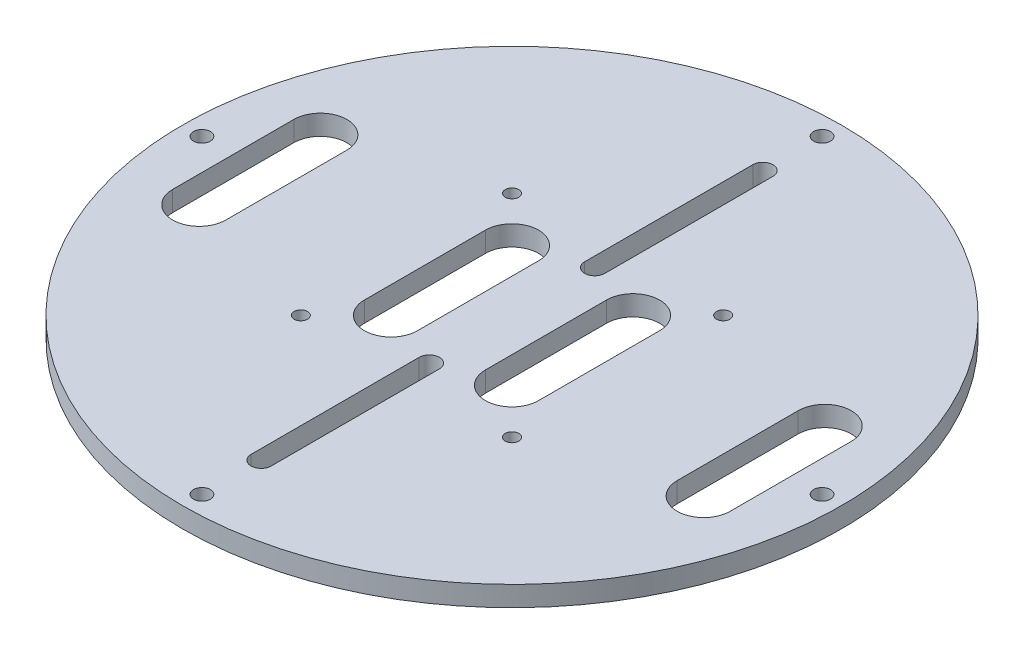
from build123d import *

# Parameters (mm, degrees)
SKETCH_1_R                      = 49
EXTRUDE_1_DEPTH                 = 3
CUT_EXTRUDE_1_DEPTH             = 4
PATTERN_CIRCULAR_2_COUNT        = 2
CUT_EXTRUDE_3_DEPTH             = 4
PATTERN_LINEAR_1_COUNT          = 2
PATTERN_LINEAR_1_PITCH          = 28.5
PATTERN_CIRCULAR_5_COUNT        = 2
PATTERN_CIRCULAR_5_COPY_1_DEPTH = 4
SKETCH_14_R                     = 1.25
CUT_EXTRUDE_4_DEPTH             = 4
PATTERN_CIRCULAR_6_COUNT        = 4
SKETCH_8_R                      = 1
CUT_EXTRUDE_5_DEPTH             = 4
PATTERN_CIRCULAR_7_COUNT        = 4


with BuildPart() as part:
    # 草图1 → 凸台-拉伸1 (new body)
    with BuildSketch(Plane(origin=(0, 0, 0), x_dir=(1, 0, 0), z_dir=(0, 1, 0))):
        Circle(SKETCH_1_R)
    extrude(amount=EXTRUDE_1_DEPTH)

    # 草图6 → 切除-拉伸1 (cut, through all)
    with BuildSketch(Plane(origin=(0, 3, 0), x_dir=(1, 0, 0), z_dir=(0, 1, 0))):
        with BuildLine():
            Line((-1.5, 12.3), (-1.5, 37.3))
            ThreePointArc((-1.5, 37.3), (0, 38.8), (1.5, 37.3))
            Line((1.5, 37.3), (1.5, 12.3))
            ThreePointArc((1.5, 12.3), (0, 10.8), (-1.5, 12.3))
        make_face()
    cut_extrude_1 = extrude(amount=-CUT_EXTRUDE_1_DEPTH, mode=Mode.SUBTRACT)

    # 阵列(圆周)2: 切除-拉伸1 ×2 about axis
    pattern_circular_2_axis = Axis((0, 0, 0), (0, 1, 0))
    for i in range(1, PATTERN_CIRCULAR_2_COUNT):
        add(cut_extrude_1.rotate(pattern_circular_2_axis, i * 360 / PATTERN_CIRCULAR_2_COUNT), mode=Mode.SUBTRACT)

    # 草图9 → 切除-拉伸3 (cut, through all)
    with BuildSketch(Plane(origin=(0, 3, 0), x_dir=(1, 0, 0), z_dir=(0, 1, 0))):
        with BuildLine():
            Line((-12.95, -9), (-12.95, 9))
            ThreePointArc((-12.95, 9), (-9, 12.95), (-5.05, 9))
            Line((-5.05, 9), (-5.05, -9))
            ThreePointArc((-5.05, -9), (-9, -12.95), (-12.95, -9))
        make_face()
    cut_extrude_3 = extrude(amount=-CUT_EXTRUDE_3_DEPTH, mode=Mode.SUBTRACT)

    # 阵列(线性)1: 切除-拉伸3 ×2
    with Locations(*[(-i * PATTERN_LINEAR_1_PITCH, 0, 0) for i in range(1, PATTERN_LINEAR_1_COUNT)]):
        add(cut_extrude_3, mode=Mode.SUBTRACT)

    # 阵列(圆周)5: 切除-拉伸3 ×2 about axis
    pattern_circular_5_axis = Axis((0, 0, 0), (0, 1, 0))
    for i in range(1, PATTERN_CIRCULAR_5_COUNT):
        add(cut_extrude_3.rotate(pattern_circular_5_axis, i * 360 / PATTERN_CIRCULAR_5_COUNT), mode=Mode.SUBTRACT)

    # 阵列(圆周)5 copy 1 sketch → 阵列(圆周)5 copy 1 (cut, through all)
    with BuildSketch(Plane(origin=(28.5, 3, 0), x_dir=(-1, 0, 0), z_dir=(0, 1, 0))):
        with BuildLine():
            Line((-12.95, -9), (-12.95, 9))
            ThreePointArc((-12.95, 9), (-9, 12.95), (-5.05, 9))
            Line((-5.05, 9), (-5.05, -9))
            ThreePointArc((-5.05, -9), (-9, -12.95), (-12.95, -9))
        make_face()
    extrude(amount=-PATTERN_CIRCULAR_5_COPY_1_DEPTH, mode=Mode.SUBTRACT)

    # 草图14 → 切除-拉伸4 (cut, through all)
    with BuildSketch(Plane(origin=(0, 3, 0), x_dir=(1, 0, 0), z_dir=(0, 1, 0))):
        with Locations((0, 46.1)):
            Circle(SKETCH_14_R)
    cut_extrude_4 = extrude(amount=-CUT_EXTRUDE_4_DEPTH, mode=Mode.SUBTRACT)

    # 阵列(圆周)6: 切除-拉伸4 ×4 about axis
    pattern_circular_6_axis = Axis((0, 0, 0), (0, 1, 0))
    for i in range(1, PATTERN_CIRCULAR_6_COUNT):
        add(cut_extrude_4.rotate(pattern_circular_6_axis, i * 360 / PATTERN_CIRCULAR_6_COUNT), mode=Mode.SUBTRACT)

    # 草图8 → 切除-拉伸5 (cut, through all)
    with BuildSketch(Plane(origin=(0, 3, 0), x_dir=(1, 0, 0), z_dir=(0, 1, 0))):
        with Locations((-15.7, 15.7)):
            Circle(SKETCH_8_R)
    cut_extrude_5 = extrude(amount=-CUT_EXTRUDE_5_DEPTH, mode=Mode.SUBTRACT)

    # 阵列(圆周)7: 切除-拉伸5 ×4 about axis
    pattern_circular_7_axis = Axis((0, 0, 0), (0, 1, 0))
    for i in range(1, PATTERN_CIRCULAR_7_COUNT):
        add(cut_extrude_5.rotate(pattern_circular_7_axis, i * 360 / PATTERN_CIRCULAR_7_COUNT), mode=Mode.SUBTRACT)


solid = part.part
